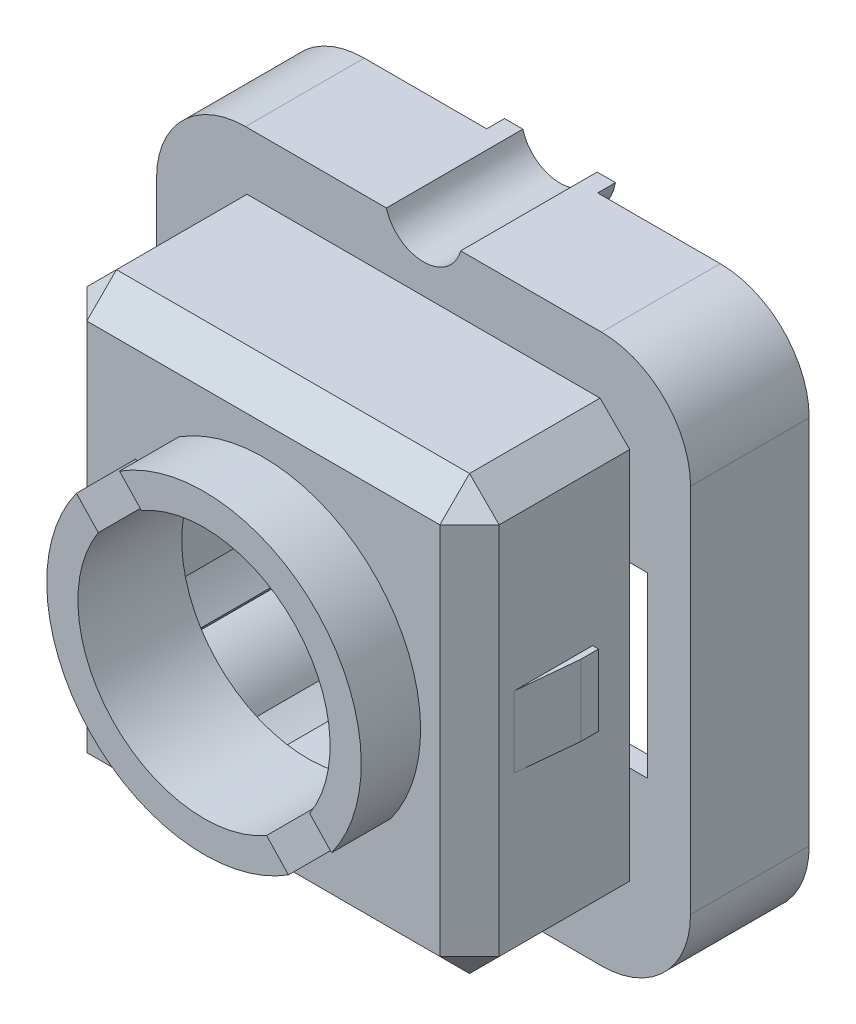
from build123d import *

# Parameters (mm, degrees)
SKETCH1_W            = 18
SKETCH1_H            = 18.5
BOSS_EXTRUDE1_DEPTH  = 3.3
SKETCH2_W            = 18
SKETCH2_H            = 18.5
BOSS_EXTRUDE2_DEPTH  = 0.7
FILLET1_R            = 3
SKETCH3_W            = 13.9
SKETCH3_H            = 14.6
BOSS_EXTRUDE3_DEPTH  = 3.9
SKETCH4_W            = 13.9
SKETCH4_H            = 14.6
SKETCH4_R            = 4.25
BOSS_EXTRUDE4_DEPTH  = 1.5
CHAMFER1_SIZE        = 1
BOSS_EXTRUDE5_DEPTH  = 2
SKETCH6_W            = 0.6
SKETCH6_H            = 6
CUT_EXTRUDE1_DEPTH   = 15.876911642
SKETCH7_W            = 0.7
SKETCH7_H            = 6
CUT_EXTRUDE2_DEPTH   = 14
SKETCH8_W            = 2.65
SKETCH8_H            = 2.4
BOSS_EXTRUDE6_DEPTH  = 0.2
SKETCH9_W            = 2.65
SKETCH9_H            = 2.4
BOSS_EXTRUDE7_DEPTH  = 0.2
CUT_EXTRUDE3_DEPTH   = 18.893085257
CUT_EXTRUDE5_START   = -7.9
CUT_EXTRUDE5_DEPTH   = 7.9
CUT_EXTRUDE7_START   = -4.6
SKETCH12_W           = 0.378675411
SKETCH12_H           = 6.25
CUT_EXTRUDE7_DEPTH   = 4.6
BOSS_EXTRUDE10_DEPTH = 3.3
FILLET2_R            = 2
BOSS_EXTRUDE11_DEPTH = 0.6
SKETCH15_R           = 1.3
CUT_EXTRUDE8_DEPTH   = 18.622783549


with BuildPart() as part:
    # Sketch1 → Boss-Extrude1 (new body)
    with BuildSketch(Plane.XY):
        Rectangle(SKETCH1_W, SKETCH1_H)
        Polygon((-3, -8.25), (-3, -3.25), (-8.2, -3.25), (-8.2, 8.25), (3, 8.25), (3, 3.25), (7.473843231, 3.25), (8.2, 3.25), (8.2, -8.25), align=None, mode=Mode.SUBTRACT)
    extrude(amount=BOSS_EXTRUDE1_DEPTH)

    # Sketch2 → Boss-Extrude2 (add)
    with BuildSketch(Plane.XY.offset(3.3)):
        Rectangle(SKETCH2_W, SKETCH2_H)
        Polygon((-6, 6.5), (3, 6.5), (3, 3.25), (6, 3.25), (6, -6.5), (-3, -6.5), (-3, -3.25), (-6, -3.25), align=None, mode=Mode.SUBTRACT)
    extrude(amount=BOSS_EXTRUDE2_DEPTH)

    # Fillet1
    fillet1_edges = [part.edges().sort_by_distance(p)[0] for p in [
        (-9, 9.25, 2),
        (9, 9.25, 2),
        (9, -9.25, 2),
        (-9, -9.25, 2),
    ]]
    fillet(fillet1_edges, radius=FILLET1_R)

    # Sketch3 → Boss-Extrude3 (add)
    with BuildSketch(Plane.XY.offset(4)):
        Rectangle(SKETCH3_W, SKETCH3_H)
        Polygon((-6, 6.5), (3, 6.5), (3, 3.25), (6, 3.25), (6, -6.5), (-3, -6.5), (-3, -3.25), (-6, -3.25), align=None, mode=Mode.SUBTRACT)
    extrude(amount=BOSS_EXTRUDE3_DEPTH)

    # Sketch4 → Boss-Extrude4 (add)
    with BuildSketch(Plane.XY.offset(7.9)):
        Rectangle(SKETCH4_W, SKETCH4_H)
        Circle(SKETCH4_R, mode=Mode.SUBTRACT)
    extrude(amount=BOSS_EXTRUDE4_DEPTH)

    # Chamfer1
    chamfer1_edges = [part.edges().sort_by_distance(p)[0] for p in [
        (-6.95, 7.3, 6.7),
        (-6.95, -7.3, 6.7),
        (6.95, -7.3, 6.7),
        (6.95, 7.3, 6.7),
        (-6.95, 0, 9.4),
        (0, -7.3, 9.4),
        (6.95, 0, 9.4),
        (0, 7.3, 9.4),
    ]]
    chamfer(chamfer1_edges, length=CHAMFER1_SIZE)

    # Sketch5 → Boss-Extrude5 (add)
    with BuildSketch(Plane.XY.offset(9.4)):
        with BuildLine():
            Line((-2.846728769, 4.470585567), (-2.109207508, 3.689680703))
            ThreePointArc((-2.109207508, 3.689680703), (3.089805898, 2.918150015), (3.563233813, -2.316433637))
            Line((3.563233813, -2.316433637), (4.300755074, -3.097338502))
            ThreePointArc((4.300755074, -3.097338502), (3.853169709, 3.639104725), (-2.846728769, 4.470585567))
        make_face()
        with BuildLine():
            Line((2.846728769, -4.470585567), (2.109207508, -3.689680703))
            ThreePointArc((2.109207508, -3.689680703), (-3.089805898, -2.918150015), (-3.563233813, 2.316433637))
            Line((-3.563233813, 2.316433637), (-4.300755074, 3.097338502))
            ThreePointArc((-4.300755074, 3.097338502), (-3.853169709, -3.639104725), (2.846728769, -4.470585567))
        make_face()
    extrude(amount=BOSS_EXTRUDE5_DEPTH)

    # Sketch6 → Cut-Extrude1 (cut, through all)
    with BuildSketch(Plane.XY.offset(4)):
        with Locations((7.25, 0)):
            Rectangle(SKETCH6_W, SKETCH6_H)
        with Locations((-7.25, 0)):
            Rectangle(SKETCH6_W, SKETCH6_H)
    extrude(amount=-CUT_EXTRUDE1_DEPTH, mode=Mode.SUBTRACT)

    # Sketch7 → Cut-Extrude2 (cut)
    with BuildSketch(Plane(origin=(6.95, 0, 0), x_dir=(0, 0, -1), z_dir=(1, 0, 0))):
        with Locations((-3.65, 0)):
            Rectangle(SKETCH7_W, SKETCH7_H)
    extrude(amount=-CUT_EXTRUDE2_DEPTH, mode=Mode.SUBTRACT)

    # Sketch8 → Boss-Extrude6 (add)
    with BuildSketch(Plane(origin=(6.95, 0, 0), x_dir=(0, 0, -1), z_dir=(1, 0, 0))):
        with Locations((-6.575, 0)):
            Rectangle(SKETCH8_W, SKETCH8_H)
    extrude(amount=BOSS_EXTRUDE6_DEPTH)

    # Sketch9 → Boss-Extrude7 (add)
    with BuildSketch(Plane.ZY.offset(6.95)):
        with Locations((6.575, 0)):
            Rectangle(SKETCH9_W, SKETCH9_H)
    extrude(amount=BOSS_EXTRUDE7_DEPTH)

    # Sketch10 → Cut-Extrude3 (cut, through all)
    with BuildSketch(Plane.XZ.offset(1.2)):
        Polygon((-6.95, 7.9), (-7.15, 5.85), (-7.15, 7.9), align=None)
        Polygon((6.95, 7.9), (7.15, 5.85), (7.15, 7.9), align=None)
    extrude(amount=-CUT_EXTRUDE3_DEPTH, mode=Mode.SUBTRACT)

    # Sketch11 → Cut-Extrude5 (cut)
    with BuildSketch(Plane(origin=(0, 0, 0), x_dir=(-1, 0, 0), z_dir=(0, 0, -1)).offset(CUT_EXTRUDE5_START)):
        with BuildLine():
            Line((-4.578389967, 6.802818924), (-3.862648789, 6.027432648))
            ThreePointArc((-3.862648789, 6.027432648), (-3.439450113, 6.278549428), (-3, 6.5))
            Line((-3, 6.5), (-3, 3.25))
            Line((-3, 3.25), (-6.378675411, 3.25))
            ThreePointArc((-6.378675411, 3.25), (-6.063337952, 3.806039001), (-5.699657401, 4.331732391))
            Line((-5.699657401, 4.331732391), (-6.415398578, 5.107118667))
            ThreePointArc((-6.415398578, 5.107118667), (-5.290584801, 5.731466868), (-4.578389967, 6.802818924))
        make_face()
        with BuildLine():
            Line((4.578389967, -6.802818924), (3.862648789, -6.027432648))
            ThreePointArc((3.862648789, -6.027432648), (3.439450113, -6.278549428), (3, -6.5))
            Line((3, -6.5), (3, -3.25))
            Line((3, -3.25), (6.378675411, -3.25))
            ThreePointArc((6.378675411, -3.25), (6.063337952, -3.806039001), (5.699657401, -4.331732391))
            Line((5.699657401, -4.331732391), (6.415398578, -5.107118667))
            ThreePointArc((6.415398578, -5.107118667), (5.290584801, -5.731466868), (4.578389967, -6.802818924))
        make_face()
    extrude(amount=CUT_EXTRUDE5_DEPTH, mode=Mode.SUBTRACT)

    # Sketch12 → Cut-Extrude7 (cut)
    with BuildSketch(Plane(origin=(0, 0, 3.3), x_dir=(-1, 0, 0), z_dir=(0, 0, -1)).offset(CUT_EXTRUDE7_START)):
        with Locations((-6.189337705, 0.125)):
            Rectangle(SKETCH12_W, SKETCH12_H)
        with Locations((6.189337705, -0.125)):
            Rectangle(SKETCH12_W, SKETCH12_H)
    extrude(amount=CUT_EXTRUDE7_DEPTH, mode=Mode.SUBTRACT)

    # Sketch13 → Boss-Extrude10 (add)
    with BuildSketch(Plane(origin=(0, 0, 0), x_dir=(-1, 0, 0), z_dir=(0, 0, -1))):
        with BuildLine():
            Line((-1.342004098, -8.25), (1.342004098, -8.25))
            ThreePointArc((1.342004098, -8.25), (0, -7.69645725), (-1.342004098, -8.25))
        make_face()
        with BuildLine():
            Line((-1.342004098, 8.25), (1.342004098, 8.25))
            ThreePointArc((1.342004098, 8.25), (0, 7.695), (-1.342004098, 8.25))
        make_face()
    extrude(amount=-BOSS_EXTRUDE10_DEPTH)

    # Fillet2
    fillet2_edges = [part.edges().sort_by_distance(p)[0] for p in [
        (-8.2, 8.25, 1.65),
        (8.2, -8.25, 1.65),
    ]]
    fillet(fillet2_edges, radius=FILLET2_R)

    # Sketch14 → Boss-Extrude11 (add)
    with BuildSketch(Plane(origin=(0, 0, 0), x_dir=(-1, 0, 0), z_dir=(0, 0, -1))):
        with BuildLine():
            Line((-1.871089255, -9.25), (1.871089255, -9.25))
            ThreePointArc((1.871089255, -9.25), (0, -7.69645725), (-1.871089255, -9.25))
        make_face()
        with BuildLine():
            Line((-1.871089255, 9.25), (1.871089255, 9.25))
            ThreePointArc((1.871089255, 9.25), (0, 7.69645725), (-1.871089255, 9.25))
        make_face()
    extrude(amount=BOSS_EXTRUDE11_DEPTH)

    # Sketch15 → Cut-Extrude8 (cut, through all)
    with BuildSketch(Plane(origin=(0, 0, -0.6), x_dir=(-1, 0, 0), z_dir=(0, 0, -1))):
        with Locations((0, 9.6)):
            Circle(SKETCH15_R)
        with Locations((0, -9.6)):
            Circle(SKETCH15_R)
    extrude(amount=-CUT_EXTRUDE8_DEPTH, mode=Mode.SUBTRACT)


solid = part.part
